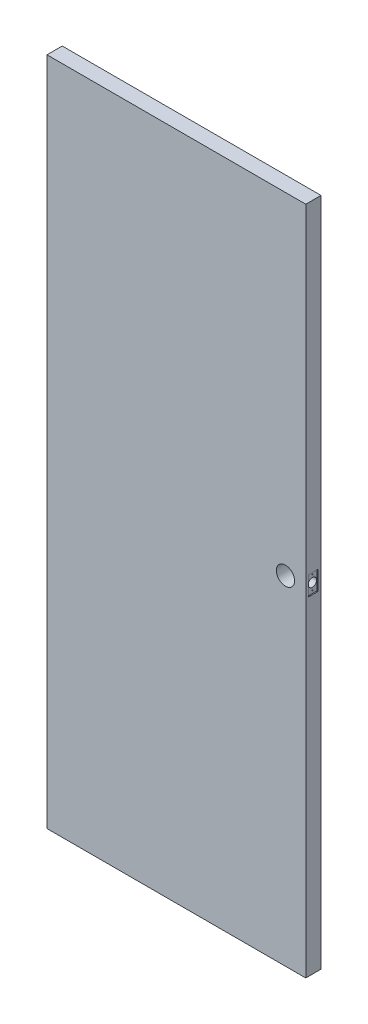
from build123d import *

# Parameters (mm, degrees)
SKETCH1_W           = 765
SKETCH1_H           = 1981
BOSS_EXTRUDE1_DEPTH = 45
SKETCH2_R           = 27
CUT_EXTRUDE1_DEPTH  = 46
CUT_EXTRUDE2_REACH  = 767
SKETCH3_R           = 12.5
SKETCH4_W           = 28.5
SKETCH4_H           = 57
CUT_EXTRUDE3_DEPTH  = 3
SKETCH5_R           = 1.5
CUT_EXTRUDE4_DEPTH  = 15


with BuildPart() as part:
    # Sketch1 → Boss-Extrude1 (new body)
    with BuildSketch(Plane.XY):
        with Locations((382.5, 990.5)):
            Rectangle(SKETCH1_W, SKETCH1_H)
    extrude(amount=BOSS_EXTRUDE1_DEPTH)

    # Sketch2 → Cut-Extrude1 (cut, through all)
    with BuildSketch(Plane.XY.offset(45)):
        with Locations((705, 1000)):
            Circle(SKETCH2_R)
    extrude(amount=-CUT_EXTRUDE1_DEPTH, mode=Mode.SUBTRACT)

    # Sketch3 → Cut-Extrude2 (cut, up to next)
    with BuildSketch(Plane(origin=(765, 0, 0), x_dir=(0, 0, -1), z_dir=(1, 0, 0)), mode=Mode.PRIVATE) as cut_extrude2_sk1:
        with Locations((-22.5, 1000)):
            Circle(SKETCH3_R)
    cut_extrude2_tool1 = extrude(cut_extrude2_sk1.sketch, amount=-CUT_EXTRUDE2_REACH, mode=Mode.PRIVATE) & part.part
    add(cut_extrude2_tool1.solids().sort_by_distance((765, 1000, 22.5))[0], mode=Mode.SUBTRACT)

    # Sketch4 → Cut-Extrude3 (cut)
    with BuildSketch(Plane(origin=(765, 0, 0), x_dir=(0, 0, -1), z_dir=(1, 0, 0))):
        with Locations((-22.5, 1000)):
            Rectangle(SKETCH4_W, SKETCH4_H)
    extrude(amount=-CUT_EXTRUDE3_DEPTH, mode=Mode.SUBTRACT)

    # Sketch5 → Cut-Extrude4 (cut)
    with BuildSketch(Plane(origin=(762, 0, 0), x_dir=(0, 0, -1), z_dir=(1, 0, 0))):
        with Locations((-22.5, 1020.5)):
            Circle(SKETCH5_R)
        with Locations((-22.5, 979.5)):
            Circle(SKETCH5_R)
    extrude(amount=-CUT_EXTRUDE4_DEPTH, mode=Mode.SUBTRACT)


solid = part.part
